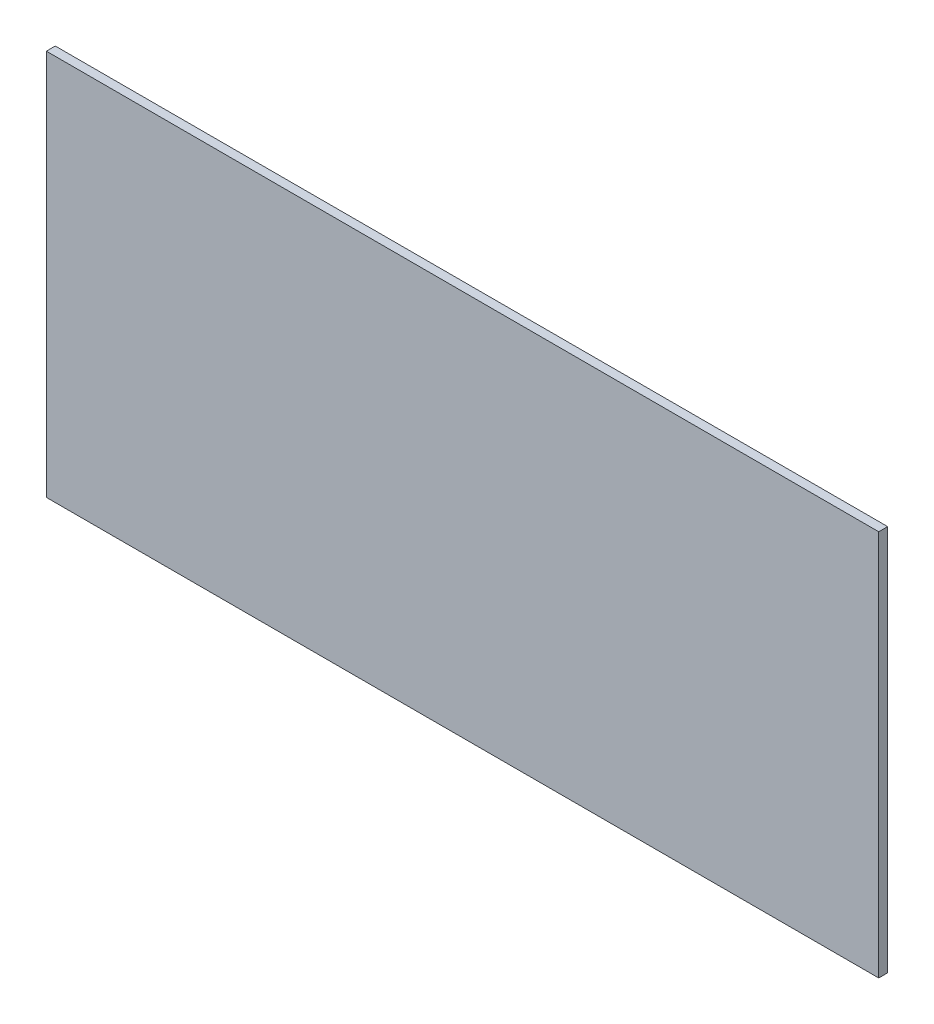
from build123d import *

# Parameters (mm, degrees)
SKETCH1_W           = 280
SKETCH1_H           = 130
BOSS_EXTRUDE1_DEPTH = 3


with BuildPart() as part:
    # Sketch1 → Boss-Extrude1 (new body)
    with BuildSketch(Plane.XY):
        with Locations((0, 708.088839574)):
            Rectangle(SKETCH1_W, SKETCH1_H)
    extrude(amount=-BOSS_EXTRUDE1_DEPTH)


solid = part.part
